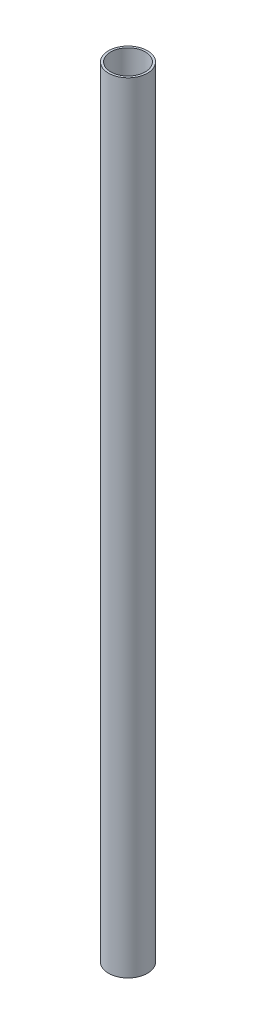
from build123d import *

# Parameters (mm, degrees)
SKETCH1_R           = 6.35
SKETCH1_R_2         = 5.6388
BOSS_EXTRUDE1_DEPTH = 254


with BuildPart() as part:
    # Sketch1 → Boss-Extrude1 (new body)
    with BuildSketch(Plane(origin=(0, 0, 0), x_dir=(1, 0, 0), z_dir=(0, 1, 0))):
        Circle(SKETCH1_R)
        Circle(SKETCH1_R_2, mode=Mode.SUBTRACT)
    extrude(amount=BOSS_EXTRUDE1_DEPTH)


solid = part.part
